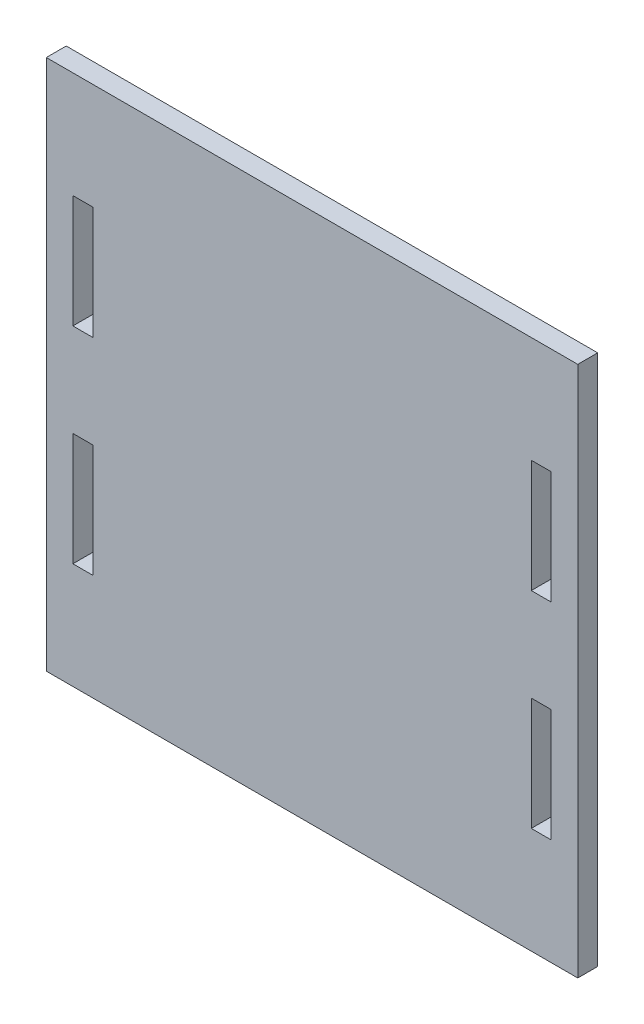
from build123d import *

# Parameters (mm, degrees)
SKETCH1_W           = 4.7625
SKETCH1_H           = 26.974800888
SKETCH1_H_2         = 26.974800889
BOSS_EXTRUDE1_DEPTH = 4.7625


with BuildPart() as part:
    # Sketch1 → Boss-Extrude1 (new body)
    with BuildSketch(Plane.XY):
        Polygon((65.88125, 142.515737536), (127, 142.515737536), (127, 15.515737536), (0, 15.515737536), (0, 142.515737536), (61.11875, 142.515737536), align=None)
        with Locations((8.73125, 103.628337092)):
            Rectangle(SKETCH1_W, SKETCH1_H, mode=Mode.SUBTRACT)
        with Locations((118.26875, 103.628337092)):
            Rectangle(SKETCH1_W, SKETCH1_H, mode=Mode.SUBTRACT)
        with Locations((118.26875, 54.403137981)):
            Rectangle(SKETCH1_W, SKETCH1_H_2, mode=Mode.SUBTRACT)
        with Locations((8.73125, 54.403137981)):
            Rectangle(SKETCH1_W, SKETCH1_H_2, mode=Mode.SUBTRACT)
    extrude(amount=BOSS_EXTRUDE1_DEPTH)


solid = part.part
